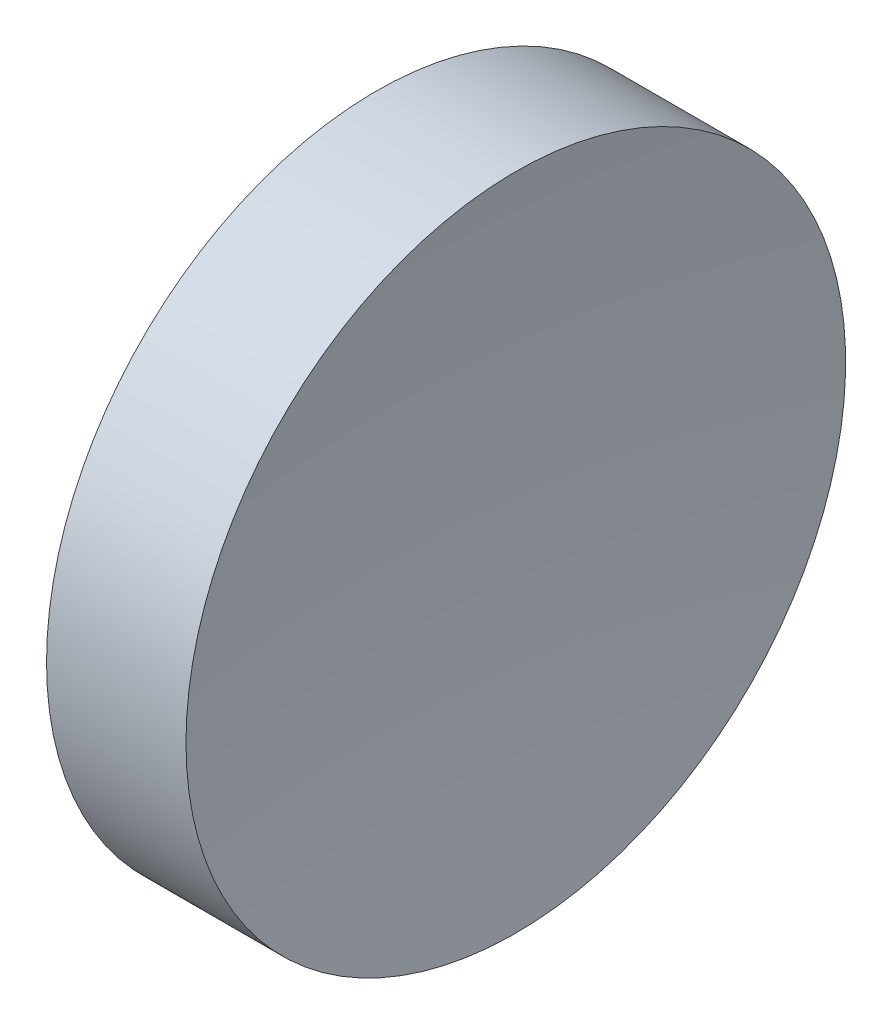
from build123d import *


with BuildPart() as part:
    # 草图1 → 旋转1 (revolve)
    with BuildSketch(Plane.XY, mode=Mode.PRIVATE) as revolve_1_sk:
        with BuildLine():
            Line((230.18531107, 138.756042247), (230.18531107, 163.756042247))
            Line((230.18531107, 163.756042247), (240.753963902, 163.756042247))
            ThreePointArc((240.753963902, 163.756042247), (239.577859803, 151.280624774), (239.185311071, 138.756042247))
            Line((239.185311071, 138.756042247), (230.18531107, 138.756042247))
        make_face()
    revolve(revolve_1_sk.sketch.rotate(Axis((217.970286004, 138.756042247, 0), (1, 0, 0)), 90), axis=Axis((217.970286004, 138.756042247, 0), (1, 0, 0)))  # turned: the seam where the file's is


solid = part.part
